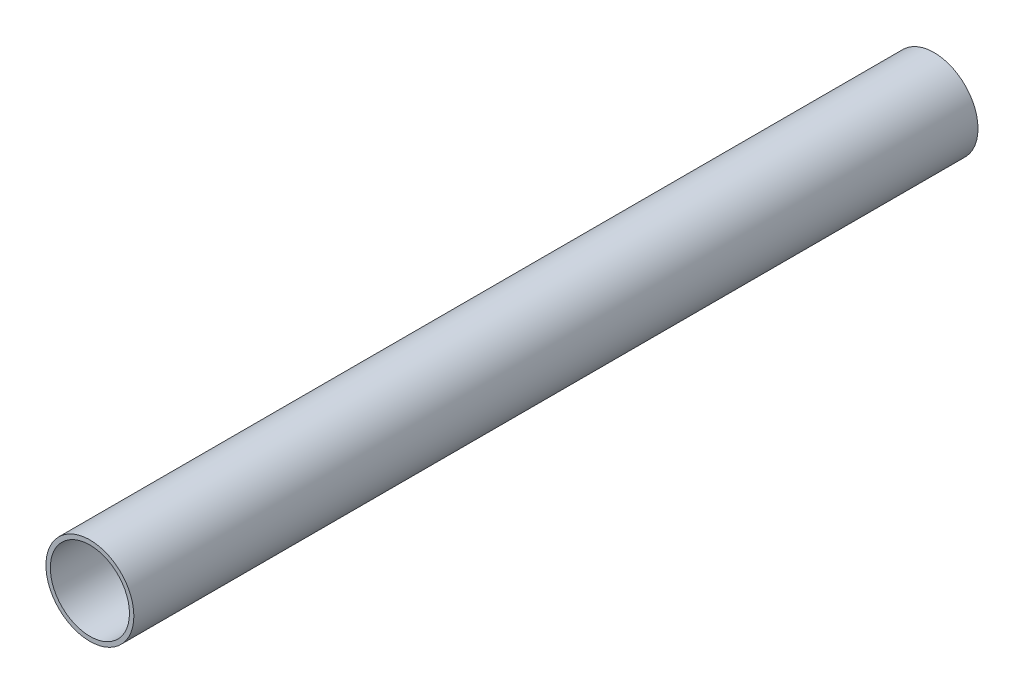
from build123d import *

# Parameters (mm, degrees)
SKETCH1_R           = 31.75
SKETCH1_R_2         = 28.575
BOSS_EXTRUDE1_DEPTH = 609.6


with BuildPart() as part:
    # Sketch1 → Boss-Extrude1 (new body)
    with BuildSketch(Plane.XY):
        Circle(SKETCH1_R)
        Circle(SKETCH1_R_2, mode=Mode.SUBTRACT)
    extrude(amount=BOSS_EXTRUDE1_DEPTH)


solid = part.part
